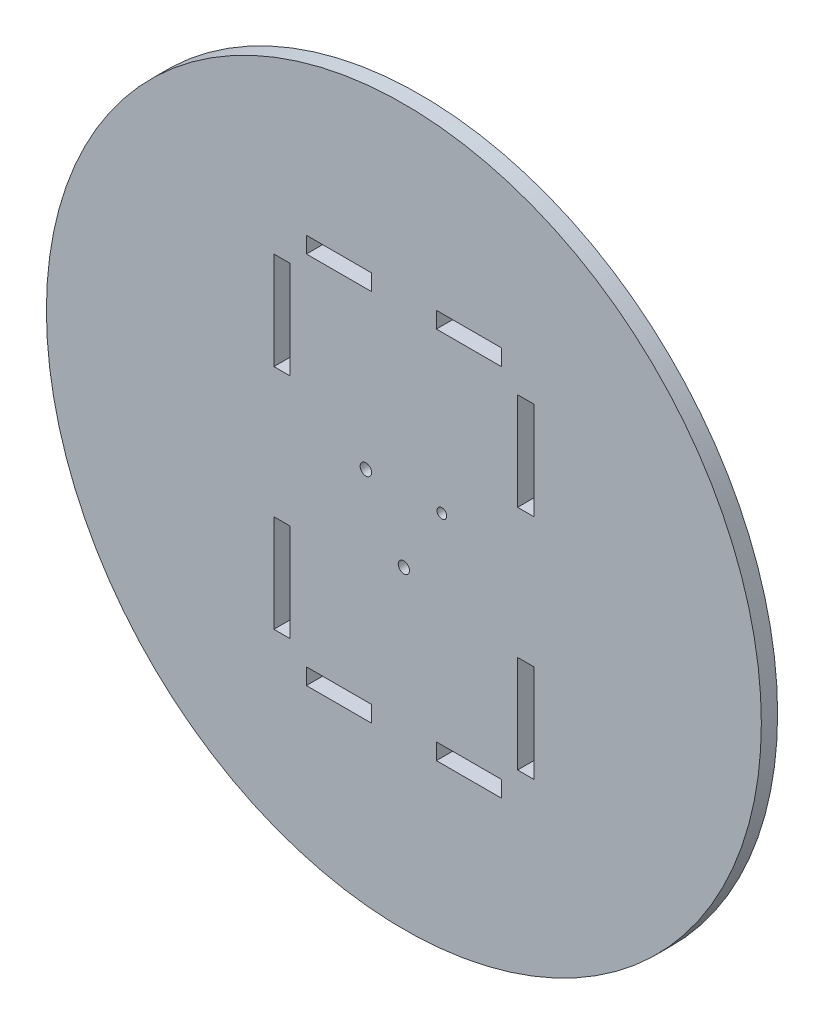
from build123d import *

# Parameters (mm, degrees)
SKETCH1_R           = 110
SKETCH1_R_2         = 1.768866344
SKETCH1_R_3         = 1.493909961
SKETCH1_R_4         = 1.739193209
SKETCH1_W           = 20
SKETCH1_H           = 5
SKETCH1_W_2         = 5
SKETCH1_H_2         = 30
BOSS_EXTRUDE1_DEPTH = 5


with BuildPart() as part:
    # Sketch1 → Boss-Extrude1 (new body)
    with BuildSketch(Plane.XY):
        Circle(SKETCH1_R)
        with Locations((-11.691342951, 6.75)):
            Circle(SKETCH1_R_2, mode=Mode.SUBTRACT)
        with Locations((11.691342951, 6.75)):
            Circle(SKETCH1_R_3, mode=Mode.SUBTRACT)
        with Locations((0, -13.5)):
            Circle(SKETCH1_R_4, mode=Mode.SUBTRACT)
        with Locations((-20, 57.5)):
            Rectangle(SKETCH1_W, SKETCH1_H, mode=Mode.SUBTRACT)
        with Locations((20, 57.5)):
            Rectangle(SKETCH1_W, SKETCH1_H, mode=Mode.SUBTRACT)
        with Locations((37.5, 35)):
            Rectangle(SKETCH1_W_2, SKETCH1_H_2, mode=Mode.SUBTRACT)
        with Locations((37.5, -35)):
            Rectangle(SKETCH1_W_2, SKETCH1_H_2, mode=Mode.SUBTRACT)
        with Locations((20, -57.5)):
            Rectangle(SKETCH1_W, SKETCH1_H, mode=Mode.SUBTRACT)
        with Locations((-20, -57.5)):
            Rectangle(SKETCH1_W, SKETCH1_H, mode=Mode.SUBTRACT)
        with Locations((-37.5, -35)):
            Rectangle(SKETCH1_W_2, SKETCH1_H_2, mode=Mode.SUBTRACT)
        with Locations((-37.5, 35)):
            Rectangle(SKETCH1_W_2, SKETCH1_H_2, mode=Mode.SUBTRACT)
    extrude(amount=BOSS_EXTRUDE1_DEPTH)


solid = part.part
